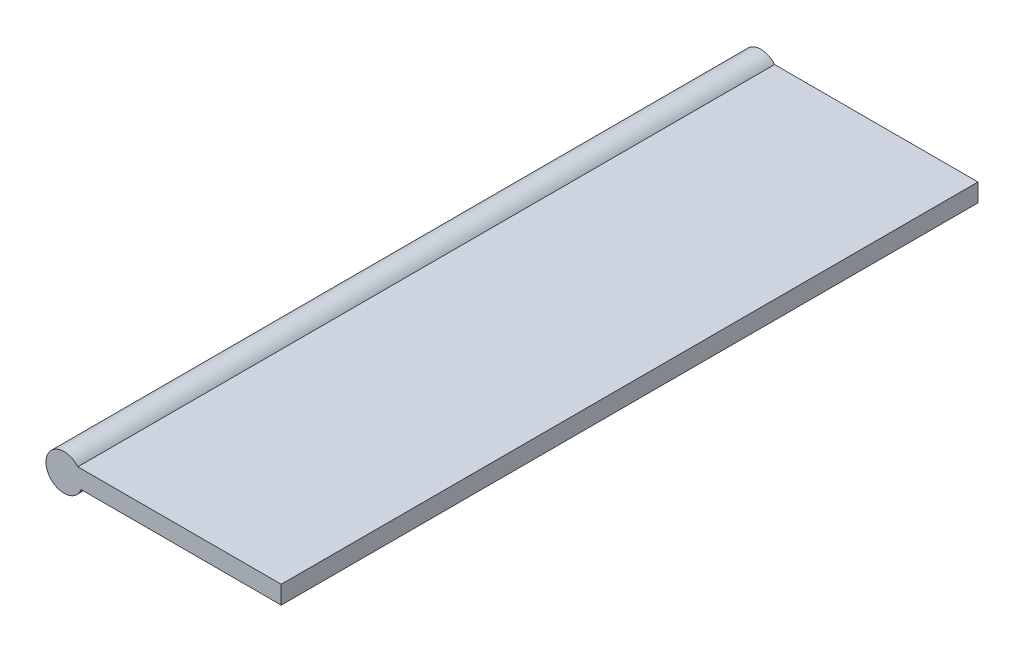
from build123d import *

# Parameters (mm, degrees)
SKETCH1_R           = 2.54
BOSS_EXTRUDE1_DEPTH = 97.79
SKETCH2_W           = 97.79
SKETCH2_H           = 2.54
BOSS_EXTRUDE2_DEPTH = 30.48


with BuildPart() as part:
    # Sketch1 → Boss-Extrude1 (new body)
    with BuildSketch(Plane.XY):
        Circle(SKETCH1_R)
    extrude(amount=BOSS_EXTRUDE1_DEPTH)

    # Sketch2 → Boss-Extrude2 (add)
    with BuildSketch(Plane(origin=(0, 0, 0), x_dir=(0, 0, -1), z_dir=(1, 0, 0))):
        with Locations((-48.895, 0.380186804)):
            Rectangle(SKETCH2_W, SKETCH2_H)
    extrude(amount=BOSS_EXTRUDE2_DEPTH)


solid = part.part
